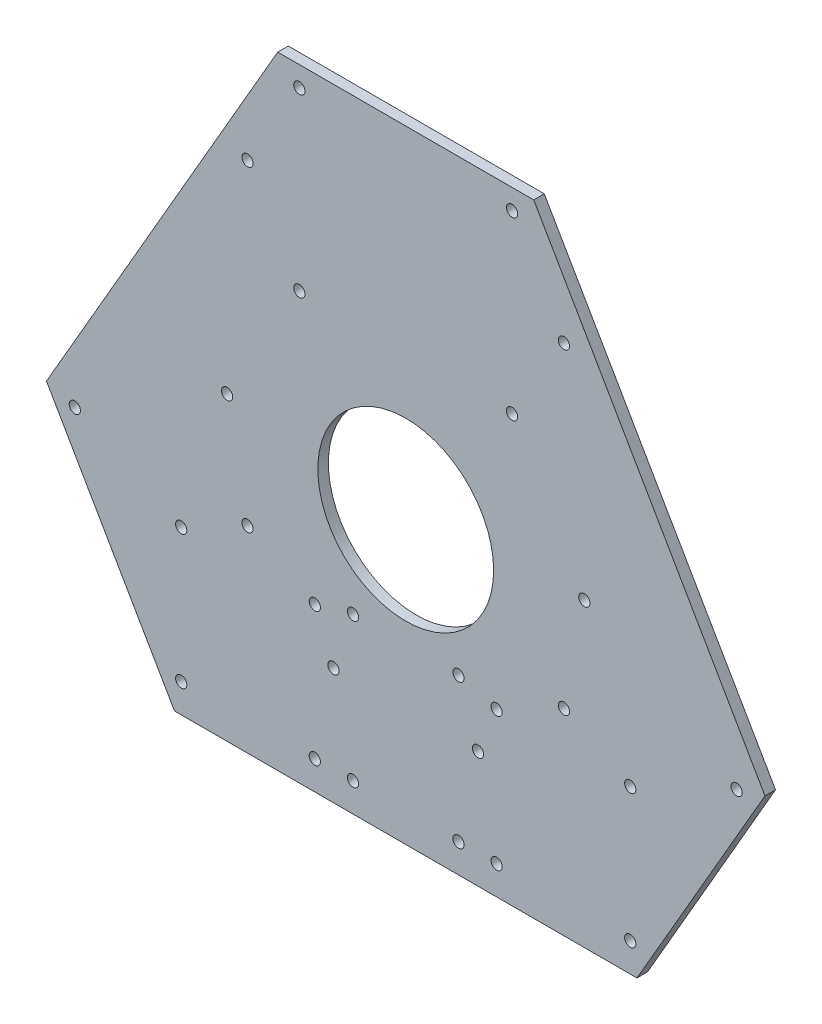
from build123d import *

# Parameters (mm, degrees)
SKETCH_1_R          = 1.6
SKETCH_1_R_2        = 25
EXTRUDE_1_DEPTH     = 3
SKETCH_2_R          = 1.6
CUT_EXTRUDE_1_DEPTH = 4


with BuildPart() as part:
    # ｽｹｯﾁ1 → ﾎﾞｽ - 押し出し1 (new body)
    with BuildSketch(Plane.XY):
        Polygon((-36.39879245, 96.955442142), (36.39879245, 96.955442142), (102.165272155, -16.955442142), (65.766479705, -80), (-65.766479705, -80), (-102.165272155, -16.955442142), align=None)
        with Locations((30.25, 91.195498156)):
            Circle(SKETCH_1_R, mode=Mode.SUBTRACT)
        with Locations((30.25, 41.195498156)):
            Circle(SKETCH_1_R, mode=Mode.SUBTRACT)
        with Locations((-30.25, 41.195498156)):
            Circle(SKETCH_1_R, mode=Mode.SUBTRACT)
        with Locations((-30.25, 91.195498156)):
            Circle(SKETCH_1_R, mode=Mode.SUBTRACT)
        with Locations((63.852618114, -71.795017542)):
            Circle(SKETCH_1_R, mode=Mode.SUBTRACT)
        with Locations((94.102618114, -19.400480613)):
            Circle(SKETCH_1_R, mode=Mode.SUBTRACT)
        with Locations((50.801347925, 5.599519387)):
            Circle(SKETCH_1_R, mode=Mode.SUBTRACT)
        with Locations((20.551347925, -46.795017542)):
            Circle(SKETCH_1_R, mode=Mode.SUBTRACT)
        with Locations((-94.102618114, -19.400480613)):
            Circle(SKETCH_1_R, mode=Mode.SUBTRACT)
        with Locations((-63.852618114, -71.795017542)):
            Circle(SKETCH_1_R, mode=Mode.SUBTRACT)
        with Locations((-20.551347925, -46.795017542)):
            Circle(SKETCH_1_R, mode=Mode.SUBTRACT)
        with Locations((-50.801347925, 5.599519387)):
            Circle(SKETCH_1_R, mode=Mode.SUBTRACT)
        Circle(SKETCH_1_R_2, mode=Mode.SUBTRACT)
    extrude(amount=EXTRUDE_1_DEPTH)

    # ｽｹｯﾁ2 → ｶｯﾄ - 押し出し1 (cut, through all)
    with BuildSketch(Plane(origin=(0, 0, 0), x_dir=(-1, 0, 0), z_dir=(0, 0, -1))):
        with Locations((-63.852618114, -33.795017542)):
            Circle(SKETCH_2_R)
        with Locations((-25.852618114, -33.795017542)):
            Circle(SKETCH_2_R)
        with Locations((-25.852618114, -71.795017542)):
            Circle(SKETCH_2_R)
        with Locations((-63.852618114, -71.795017542)):
            Circle(SKETCH_2_R)
        with Locations((15, -30.795017542)):
            Circle(SKETCH_2_R)
        with Locations((-15, -30.795017542)):
            Circle(SKETCH_2_R)
        with Locations((-15, -71.795017542)):
            Circle(SKETCH_2_R)
        with Locations((15, -71.795017542)):
            Circle(SKETCH_2_R)
        with Locations((45, 66)):
            Circle(SKETCH_2_R)
        with Locations((-45, 66)):
            Circle(SKETCH_2_R)
        with Locations((-45, -24)):
            Circle(SKETCH_2_R)
        with Locations((45, -24)):
            Circle(SKETCH_2_R)
        with Locations((63.852618114, -71.795017542)):
            Circle(SKETCH_2_R)
        with Locations((25.852618114, -71.795017542)):
            Circle(SKETCH_2_R)
        with Locations((25.852618114, -33.795017542)):
            Circle(SKETCH_2_R)
        with Locations((63.852618114, -33.795017542)):
            Circle(SKETCH_2_R)
    extrude(amount=-CUT_EXTRUDE_1_DEPTH, mode=Mode.SUBTRACT)


solid = part.part
